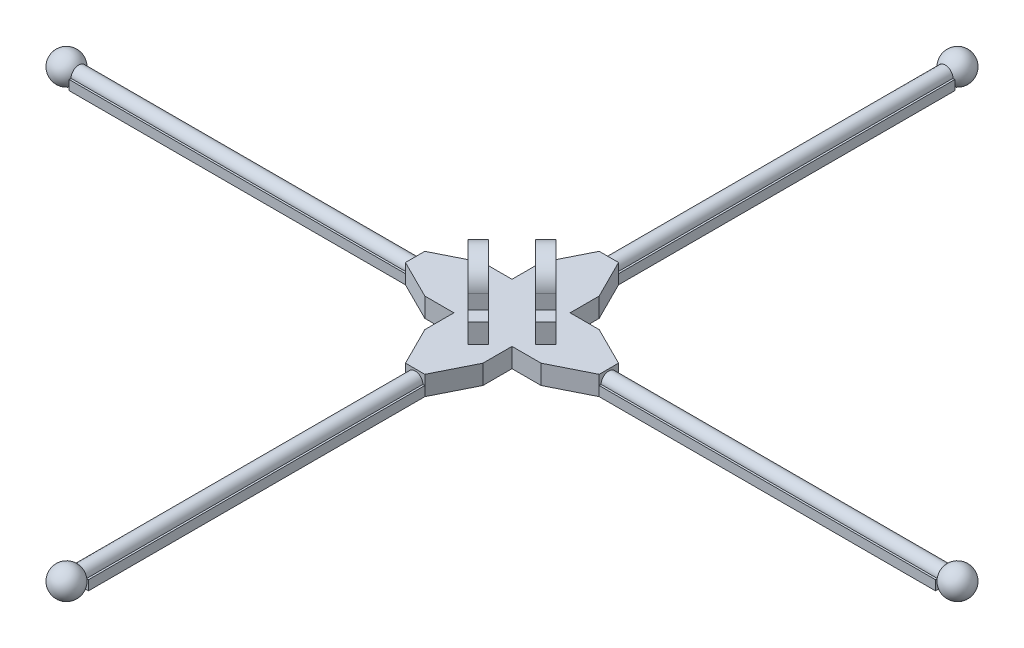
from build123d import *

# Parameters (mm, degrees)
EXTRUDE_1_DEPTH     = 2
SKETCH_2_R          = 0.8
CUT_EXTRUDE_1_DEPTH = 4
SKETCH_3_R          = 0.8
CUT_EXTRUDE_2_DEPTH = 4
SKETCH_4_R          = 0.8
CUT_EXTRUDE_3_DEPTH = 4
SKETCH_5_R          = 0.8
CUT_EXTRUDE_4_DEPTH = 4
SKETCH_9_R          = 1.5
EXTRUDE_2_DEPTH     = 1.5
SKETCH_10_R         = 0.8
EXTRUDE_3_DEPTH     = 40
SKETCH_11_R         = 0.8
EXTRUDE_4_DEPTH     = 40
SKETCH_15_W         = 2
SKETCH_15_H         = 34.731142246
SKETCH_15_W_2       = 34.731142246
SKETCH_15_H_2       = 2
EXTRUDE_6_DEPTH     = 1


with BuildPart() as part:
    # 草图1 → 凸台-拉伸1 (new body)
    with BuildSketch(Plane(origin=(0, 0, 0), x_dir=(1, 0, 0), z_dir=(0, 1, 0))):
        Polygon((3, -3), (6, -3), (10, -1), (10, 1), (6, 3), (3, 3), (3, 6), (1, 10), (-1, 10), (-3, 6), (-3, 3), (-6, 3), (-10, 1), (-10, -1), (-6, -3), (-3, -3), (-3, -6), (-1, -10), (1, -10), (3, -6), align=None)
    extrude(amount=EXTRUDE_1_DEPTH)

    # 草图2 → 切除-拉伸1 (cut)
    with BuildSketch(Plane.XY.offset(10)):
        with Locations((0, 1)):
            Circle(SKETCH_2_R)
    extrude(amount=-CUT_EXTRUDE_1_DEPTH, mode=Mode.SUBTRACT)

    # 草图3 → 切除-拉伸2 (cut)
    with BuildSketch(Plane(origin=(10, 0, 0), x_dir=(0, 0, -1), z_dir=(1, 0, 0))):
        with Locations((0, 1)):
            Circle(SKETCH_3_R)
    extrude(amount=-CUT_EXTRUDE_2_DEPTH, mode=Mode.SUBTRACT)

    # 草图4 → 切除-拉伸3 (cut)
    with BuildSketch(Plane(origin=(0, 0, -10), x_dir=(-1, 0, 0), z_dir=(0, 0, -1))):
        with Locations((0, 1)):
            Circle(SKETCH_4_R)
    extrude(amount=-CUT_EXTRUDE_3_DEPTH, mode=Mode.SUBTRACT)

    # 草图5 → 切除-拉伸4 (cut)
    with BuildSketch(Plane.ZY.offset(10)):
        with Locations((0, 1)):
            Circle(SKETCH_5_R)
    extrude(amount=-CUT_EXTRUDE_4_DEPTH, mode=Mode.SUBTRACT)

    # 草图9 → 凸台-拉伸2 (add)
    with BuildSketch(Plane(origin=(-1.202081528, 0, 1.202081528), x_dir=(0.707106781, 0, 0.707106781), z_dir=(-0.707106781, 0, 0.707106781))):
        with BuildLine():
            Line((2.5, 5.5), (2.5, 4))
            Line((2.5, 4), (4, 4))
            Line((4, 4), (4, 2))
            Line((4, 2), (-4, 2))
            Line((-4, 2), (-4, 4))
            Line((-4, 4), (-2.5, 4))
            Line((-2.5, 4), (-2.5, 5.5))
            ThreePointArc((-2.5, 5.5), (0, 8), (2.5, 5.5))
        make_face()
        with Locations((0, 5.5)):
            Circle(SKETCH_9_R, mode=Mode.SUBTRACT)
    extrude_2 = extrude(amount=EXTRUDE_2_DEPTH)

    # 镜向1: 凸台-拉伸2 across plane
    add(extrude_2.mirror(Plane(origin=(0, 0, 0), x_dir=(0.707106781, 0, 0.707106781), z_dir=(-0.707106781, 0, 0.707106781))))

    # 草图10 → 凸台-拉伸3 (add)
    with BuildSketch(Plane.ZY.offset(6)):
        with Locations((0, 1)):
            Circle(SKETCH_10_R)
    extrude_3 = extrude(amount=EXTRUDE_3_DEPTH)

    # 草图11 → 凸台-拉伸4 (add)
    with BuildSketch(Plane.XY.offset(6)):
        with Locations((0, 1)):
            Circle(SKETCH_11_R)
    extrude_4 = extrude(amount=EXTRUDE_4_DEPTH)

    # 镜向2: 凸台-拉伸4 across plane
    add(extrude_4.mirror(Plane.XY))

    # 镜向3: 凸台-拉伸3 across plane
    add(extrude_3.mirror(Plane(origin=(0, 0, 0), x_dir=(0, 0, 1), z_dir=(1, 0, 0))))

    # 草图12 → 旋转1 (revolve)
    with BuildSketch(Plane(origin=(0, 0, 0), x_dir=(0, 0, -1), z_dir=(1, 0, 0))):
        with BuildLine():
            Line((-47.5, 1), (-44.5, 1))
            ThreePointArc((-44.5, 1), (-46, 2.5), (-47.5, 1))
        make_face()
    revolve_1 = revolve(axis=Axis((0, 1, 47.5), (0, 0, -1)))

    # 草图14 → 旋转2 (revolve)
    with BuildSketch(Plane.XY):
        with BuildLine():
            Line((-47.5, 1), (-44.5, 1))
            ThreePointArc((-44.5, 1), (-46, 2.5), (-47.5, 1))
        make_face()
    revolve_2 = revolve(axis=Axis((-47.5, 1, 0), (1, 0, 0)))

    # 镜向4: 旋转1 across plane
    add(revolve_1.mirror(Plane.XY))

    # 镜向5: 旋转2 across plane
    add(revolve_2.mirror(Plane(origin=(0, 0, 0), x_dir=(0, 0, 1), z_dir=(1, 0, 0))))

    # 草图15 → 凸台-拉伸6 (add)
    with BuildSketch(Plane(origin=(0, 0, 0), x_dir=(1, 0, 0), z_dir=(0, 1, 0))):
        with Locations((0, 27.365571123)):
            Rectangle(SKETCH_15_W, SKETCH_15_H)
        with Locations((27.365571123, 0)):
            Rectangle(SKETCH_15_W_2, SKETCH_15_H_2)
        with Locations((0, -27.365571123)):
            Rectangle(SKETCH_15_W, SKETCH_15_H)
        with Locations((-27.365571123, 0)):
            Rectangle(SKETCH_15_W_2, SKETCH_15_H_2)
    extrude(amount=EXTRUDE_6_DEPTH)


solid = part.part
